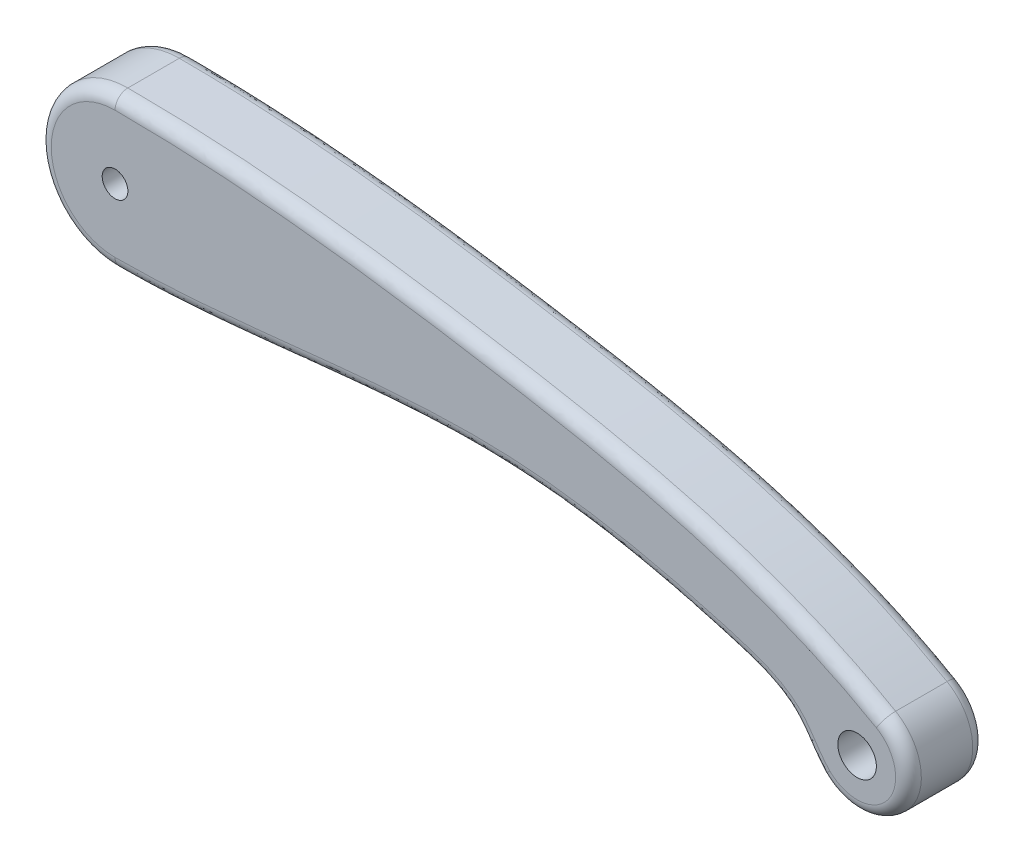
from build123d import *

# Parameters (mm, degrees)
CROQUIS1_R              = 0.5
CROQUIS1_R_2            = 0.75
SALIENTE_EXTRUIR1_DEPTH = 3
REDONDEO1_R             = 0.5
REDONDEO2_R             = 0.5


with BuildPart() as part:
    # Croquis1 → Saliente-Extruir1 (new body)
    with BuildSketch(Plane.XY):
        with BuildLine():
            ThreePointArc((0, 2.98), (-2.98, 0), (0, -2.98))
            add(Edge.make_bspline(
                [(27.45476023, -6.231976479), (26.998779658, -5.775995908), (26.376511814, -4.374157261), (21.720268516, -2.867863683), (13.141386563, -1.141319481), (4.979505917, -2.98), (0, -2.98)],
                knots=[0, 0, 0, 0, 0.062319749, 0.159605573, 0.474596605, 1, 1, 1, 1], degree=3))
            ThreePointArc((27.45476023, -6.231976479), (30.455680473, -6.035285775), (29.868973792, -3.08571211))
            add(Edge.make_bspline(
                [(29.868973792, -3.08571211), (25.223510958, -0.403652891), (15.112755473, 1.649400545), (5.186052197, 2.98), (0, 2.98)],
                knots=[0, 0, 0, 0, 0.507924163, 1, 1, 1, 1], degree=3))
        make_face()
        Circle(CROQUIS1_R, mode=Mode.SUBTRACT)
        with Locations((28.868973792, -4.817762917)):
            Circle(CROQUIS1_R_2, mode=Mode.SUBTRACT)
    extrude(amount=SALIENTE_EXTRUIR1_DEPTH)

    # Redondeo1
    redondeo1_edges = [part.edges().sort_by_distance(p)[0] for p in [
        (14.297941991, -1.988348496, 3),
        (30.455680473, -6.035285775, 3),
        (15.273685882, 1.449306751, 3),
        (-2.98, 0, 3),
    ]]
    fillet(redondeo1_edges, radius=REDONDEO1_R)

    # Redondeo2
    redondeo2_edges = [part.edges().sort_by_distance(p)[0] for p in [
        (14.297941991, -1.988348496, 0),
        (-2.98, 0, 0),
        (15.273685882, 1.449306751, 0),
        (30.455680473, -6.035285775, 0),
    ]]
    fillet(redondeo2_edges, radius=REDONDEO2_R)


solid = part.part
